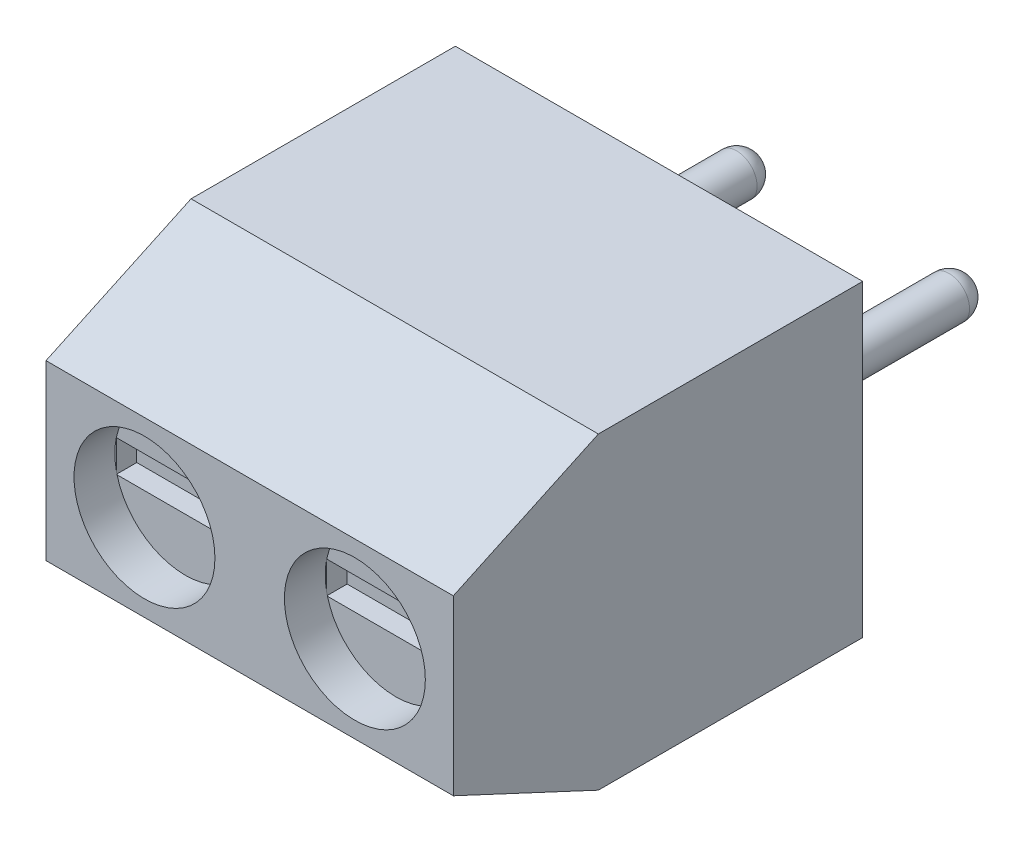
from build123d import *

# Parameters (mm, degrees)
ESQUISSE1_W             = 9.97
ESQUISSE1_H             = 7.55
EXTRUSION1_DEPTH        = 10.02
CHANFREIN1_SIZE         = 3.55
CHANFREIN1_SIZE2        = 1.655392186
CHANFREIN1_PART_2_SIZE  = 3.55
CHANFREIN1_PART_2_SIZE2 = 1.655392186
ESQUISSE2_R             = 1.725
ENL_V_MAT_EXTRU_1_DEPTH = 1
ESQUISSE3_W             = 4
ESQUISSE3_H             = 5
ENL_V_MAT_EXTRU_2_DEPTH = 1.6
ESQUISSE4_R             = 1.675
ENL_V_MAT_EXTRU_3_DEPTH = 1.6
ESQUISSE5_R             = 0.5
EXTRUSION2_DEPTH        = 5
CONG_1_R                = 0.5
ESQUISSE7_W             = 3.359641585
ESQUISSE7_H             = 0.780050821
ENL_V_MAT_EXTRU_4_DEPTH = 0.5
ESQUISSE8_W             = 3.1960084
ESQUISSE8_H             = 1.003036954
ENL_V_MAT_EXTRU_5_DEPTH = 0.5


with BuildPart() as part:
    # Esquisse1 → Extrusion1 (new body)
    with BuildSketch(Plane.XY):
        with Locations((4.985, 3.775)):
            Rectangle(ESQUISSE1_W, ESQUISSE1_H)
    extrude(amount=EXTRUSION1_DEPTH)

    # Chanfrein1
    chanfrein1_edges = [part.edges().sort_by_distance(p)[0] for p in [
        (4.985, 7.55, 10.02),
    ]]
    chanfrein1_side = [part.faces().sort_by_distance(p)[0] for p in [
        (4.985, 7.55, 5.01),
    ]]
    chamfer(chanfrein1_edges, length=CHANFREIN1_SIZE, length2=CHANFREIN1_SIZE2, reference=chanfrein1_side[0])

    # Chanfrein1 part 2
    chanfrein1_part_2_edges = [part.edges().sort_by_distance(p)[0] for p in [
        (4.985, 0, 10.02),
    ]]
    chanfrein1_part_2_side = [part.faces().sort_by_distance(p)[0] for p in [
        (4.985, 0, 5.01),
    ]]
    chamfer(chanfrein1_part_2_edges, length=CHANFREIN1_PART_2_SIZE, length2=CHANFREIN1_PART_2_SIZE2, reference=chanfrein1_part_2_side[0])

    # Esquisse2 → Enlèv. mat.-Extru.1 (cut)
    with BuildSketch(Plane.XY.offset(10.02)):
        with Locations((2.410120412, 3.775)):
            Circle(ESQUISSE2_R)
        with Locations((7.559879588, 3.775)):
            Circle(ESQUISSE2_R)
    extrude(amount=-ENL_V_MAT_EXTRU_1_DEPTH, mode=Mode.SUBTRACT)

    # Esquisse3 → Enlèv. mat.-Extru.2 (cut)
    with BuildSketch(Plane.XZ):
        with Locations((7.435, 3.3)):
            Rectangle(ESQUISSE3_W, ESQUISSE3_H)
        with Locations((2.535, 3.3)):
            Rectangle(ESQUISSE3_W, ESQUISSE3_H)
    extrude(amount=-ENL_V_MAT_EXTRU_2_DEPTH, mode=Mode.SUBTRACT)

    # Esquisse4 → Enlèv. mat.-Extru.3 (cut)
    with BuildSketch(Plane.XZ.offset(-1.6)):
        with Locations(Location((7.435, 3.235, 0), (0, 0, 270))):  # turned: the seam where the file's is
            Circle(ESQUISSE4_R)
        with Locations(Location((2.535, 3.235, 0), (0, 0, 270))):  # turned: the seam where the file's is
            Circle(ESQUISSE4_R)
    extrude(amount=-ENL_V_MAT_EXTRU_3_DEPTH, mode=Mode.SUBTRACT)

    # Esquisse5 → Extrusion2 (add)
    with BuildSketch(Plane(origin=(0, 0, 0), x_dir=(-1, 0, 0), z_dir=(0, 0, -1))):
        with Locations((-7.585, 3.775)):
            Circle(ESQUISSE5_R)
        with Locations((-2.385, 3.775)):
            Circle(ESQUISSE5_R)
    extrude(amount=EXTRUSION2_DEPTH)

    # Congé1
    cong_1_edges = [part.edges().sort_by_distance(p)[0] for p in [
        (8.085, 3.775, -5),
        (2.885, 3.775, -5),
    ]]
    fillet(cong_1_edges, radius=CONG_1_R)

    # Esquisse7 → Enlèv. mat.-Extru.4 (cut)
    with BuildSketch(Plane.XY.offset(9.02)):
        with Locations((2.40077537, 3.734751354)):
            Rectangle(ESQUISSE7_W, ESQUISSE7_H)
        with Locations((7.550534547, 3.734751354)):
            Rectangle(ESQUISSE7_W, ESQUISSE7_H)
    extrude(amount=-ENL_V_MAT_EXTRU_4_DEPTH, mode=Mode.SUBTRACT)

    # Esquisse8 → Enlèv. mat.-Extru.5 (cut)
    with BuildSketch(Plane.XZ.offset(-3.2)):
        with Locations((2.54160667, 3.256051041)):
            Rectangle(ESQUISSE8_W, ESQUISSE8_H)
        with Locations((7.44160667, 3.256051041)):
            Rectangle(ESQUISSE8_W, ESQUISSE8_H)
    extrude(amount=-ENL_V_MAT_EXTRU_5_DEPTH, mode=Mode.SUBTRACT)


solid = part.part
